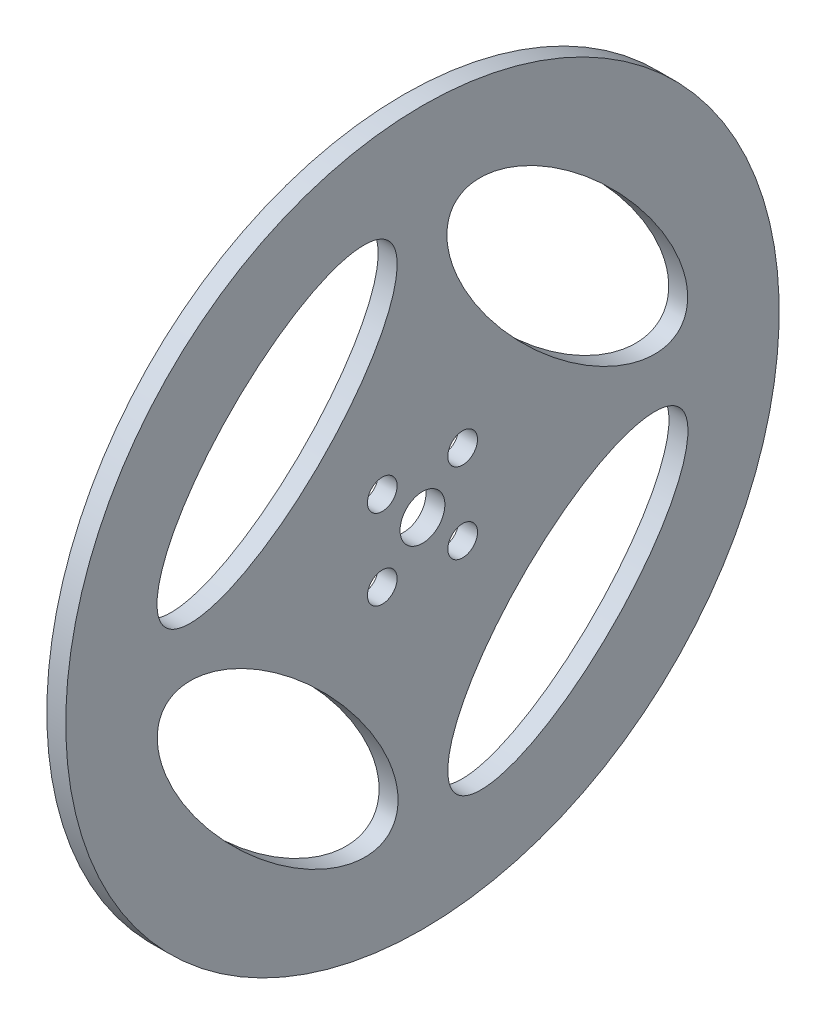
from build123d import *

# Parameters (mm, degrees)
SKIZZE1_W                        = 3
SKIZZE1_H                        = 52.95
F_4_7_4_7_DURCHMESSER_BOHRUNG1_D = 4.7
SKIZZE5_RX                       = 25
SKIZZE5_RY                       = 10
SCHNITT_LINEAR_AUSTRAGEN1_DEPTH  = 3
KREISMUSTER1_COUNT               = 4


with BuildPart() as part:
    # Skizze1 → Rotation1 (revolve)
    with BuildSketch(Plane.XY):
        with Locations((-39.553372853, 39.775)):
            Rectangle(SKIZZE1_W, SKIZZE1_H)
    revolve(axis=Axis((-17.6629112, 9.75, 0), (-1, 0, 0)))

    # Ø4.7 (4.7) Durchmesser Bohrung1 (through all)
    with Locations(Plane(origin=(-41.053372853, 11.968723204, 19.868936148), x_dir=(0, 0, 1), z_dir=(-1, 0, 0))):
        with Locations((-13.504975118, -8.582684234), (-26.232897179, -8.582684234), (-26.232897179, 4.145237827), (-13.504975118, 4.145237827)):
            Hole(F_4_7_4_7_DURCHMESSER_BOHRUNG1_D / 2)

    # Skizze5 → Schnitt-Linear austragen1 (cut)
    with BuildSketch(Plane(origin=(-38.053372853, 0, 0), x_dir=(0, 0, -1), z_dir=(1, 0, 0))):
        with Locations(Location((-23.027329597, 32.684515508), (0, 0, 45.090609512))):
            Ellipse(SKIZZE5_RX, SKIZZE5_RY)
    schnitt_linear_austragen1 = extrude(amount=-SCHNITT_LINEAR_AUSTRAGEN1_DEPTH, mode=Mode.SUBTRACT)

    # Kreismuster1: Schnitt-Linear austragen1 ×4 about axis
    kreismuster1_axis = Axis((0, 9.75, 0), (-1, 0, 0))
    for i in range(1, KREISMUSTER1_COUNT):
        add(schnitt_linear_austragen1.rotate(kreismuster1_axis, i * 360 / KREISMUSTER1_COUNT), mode=Mode.SUBTRACT)


solid = part.part
